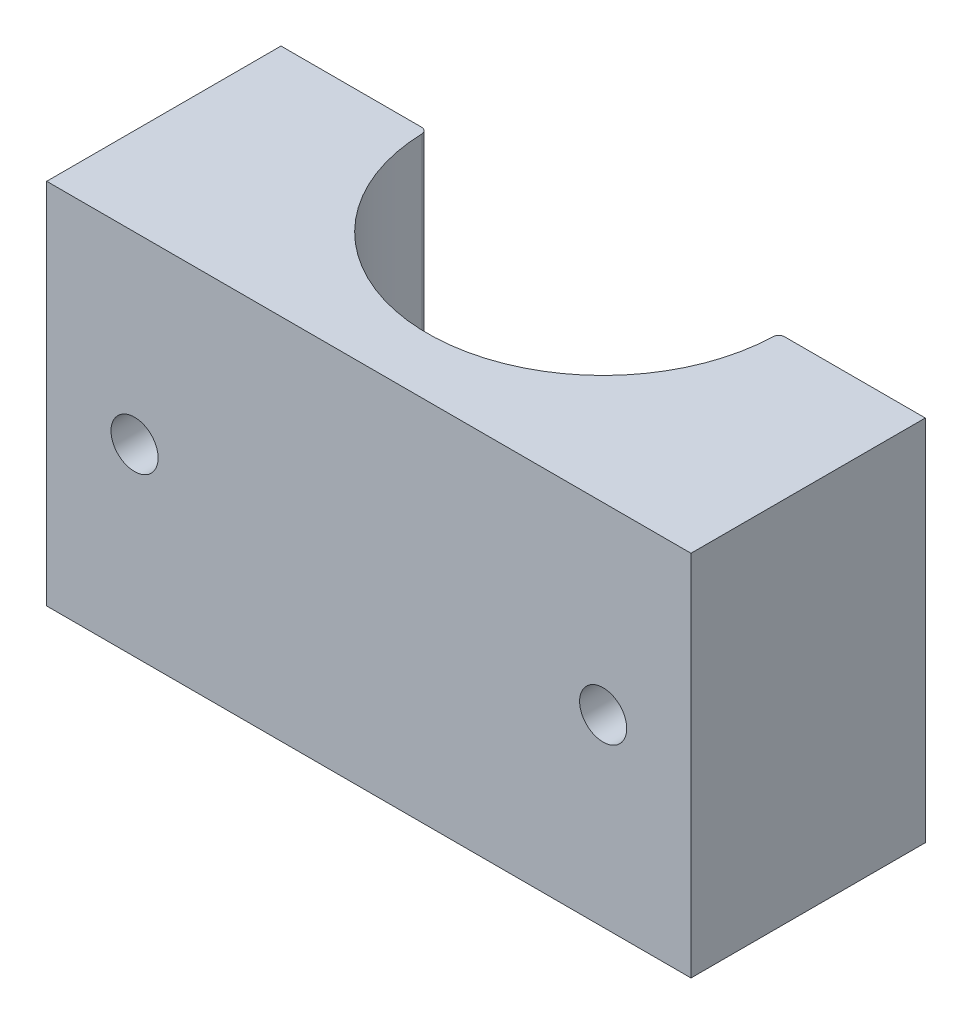
from build123d import *

# Parameters (mm, degrees)
BOSS_EXTRUDE2_DEPTH                                = 39.878
FILLET1_R                                          = 0.635
CSK_FOR_10_FLAT_HEAD_MACHINE_SCREW_100_D           = 5.1054
CSK_FOR_10_FLAT_HEAD_MACHINE_SCREW_100_CSINK_D     = 9.779
CSK_FOR_10_FLAT_HEAD_MACHINE_SCREW_100_CSINK_ANGLE = 82
F_10_0_1935_DIAMETER_HOLE2_AT_2_COUNT              = 2
F_10_0_1935_DIAMETER_HOLE2_AT_2_PITCH              = 25.4


with BuildPart() as part:
    # Sketch5 → Boss-Extrude2 (new body)
    with BuildSketch(Plane(origin=(0, 0, 0), x_dir=(1, 0, 0), z_dir=(0, 1, 0))):
        with BuildLine():
            Line((-34.925, 0), (-34.925, -25.4))
            Line((-34.925, -25.4), (34.925, -25.4))
            Line((34.925, -25.4), (34.925, 0))
            Line((34.925, 0), (19.05, 0))
            ThreePointArc((19.05, 0), (0, -19.05), (-19.05, 0))
            Line((-19.05, 0), (-34.925, 0))
        make_face()
    extrude(amount=-BOSS_EXTRUDE2_DEPTH)

    # Fillet1
    fillet1_edges = [part.edges().sort_by_distance(p)[0] for p in [
        (-19.05, -19.939, 0),
        (19.05, -19.939, 0),
    ]]
    fillet(fillet1_edges, radius=FILLET1_R)

    # CSK for #10 Flat Head Machine Screw (100)1 (through all)
    with Locations(Plane(origin=(0, 0, 0), x_dir=(-1, 0, 0), z_dir=(0, 0, -1))):
        with Locations((-25.4, -19.939)):
            csk_for_10_flat_head_machine_screw_100 = CounterSinkHole(CSK_FOR_10_FLAT_HEAD_MACHINE_SCREW_100_D / 2, CSK_FOR_10_FLAT_HEAD_MACHINE_SCREW_100_CSINK_D / 2, counter_sink_angle=CSK_FOR_10_FLAT_HEAD_MACHINE_SCREW_100_CSINK_ANGLE)

    # Sketch12 → #10 (0.1935) Diameter Hole2 (revolve, cut)
    with BuildSketch(Plane(origin=(30.1625, -7.239, 0), x_dir=(0, 1, 0), z_dir=(1, 0, 0))):
        Polygon((0, 0), (0, 14.176584928), (2.45745, 12.7), (2.45745, 0), align=None)
    f_10_0_1935_diameter_hole2 = revolve(axis=Axis((30.1625, -7.239, -6.35), (0, 0, 1)), mode=Mode.SUBTRACT)

    # #10 (0.1935) Diameter Hole2 at 2: #10 (0.1935) Diameter Hole2 ×2
    with Locations(*[(0, -i * F_10_0_1935_DIAMETER_HOLE2_AT_2_PITCH, 0) for i in range(1, F_10_0_1935_DIAMETER_HOLE2_AT_2_COUNT)]):
        add(f_10_0_1935_diameter_hole2, mode=Mode.SUBTRACT)

    # Mirror1: #10 (0.1935) Diameter Hole2, CSK for #10 Flat Head Machine Screw (100)1 across plane
    add(f_10_0_1935_diameter_hole2.mirror(Plane(origin=(0, 0, 0), x_dir=(0, 0, 1), z_dir=(1, 0, 0))), mode=Mode.SUBTRACT)
    add(csk_for_10_flat_head_machine_screw_100.mirror(Plane(origin=(0, 0, 0), x_dir=(0, 0, 1), z_dir=(1, 0, 0))), mode=Mode.SUBTRACT)

    # Mirror1 copy 1 sketch → Mirror1 copy 1 (revolve, cut)
    with BuildSketch(Plane(origin=(-30.1625, -32.639, 0), x_dir=(0, 1, 0), z_dir=(-1, 0, 0))):
        Polygon((0, 0), (0, -14.176584928), (2.45745, -12.7), (2.45745, 0), align=None)
    revolve(axis=Axis((-30.1625, -32.639, -6.35), (0, 0, -1)), mode=Mode.SUBTRACT)


solid = part.part
